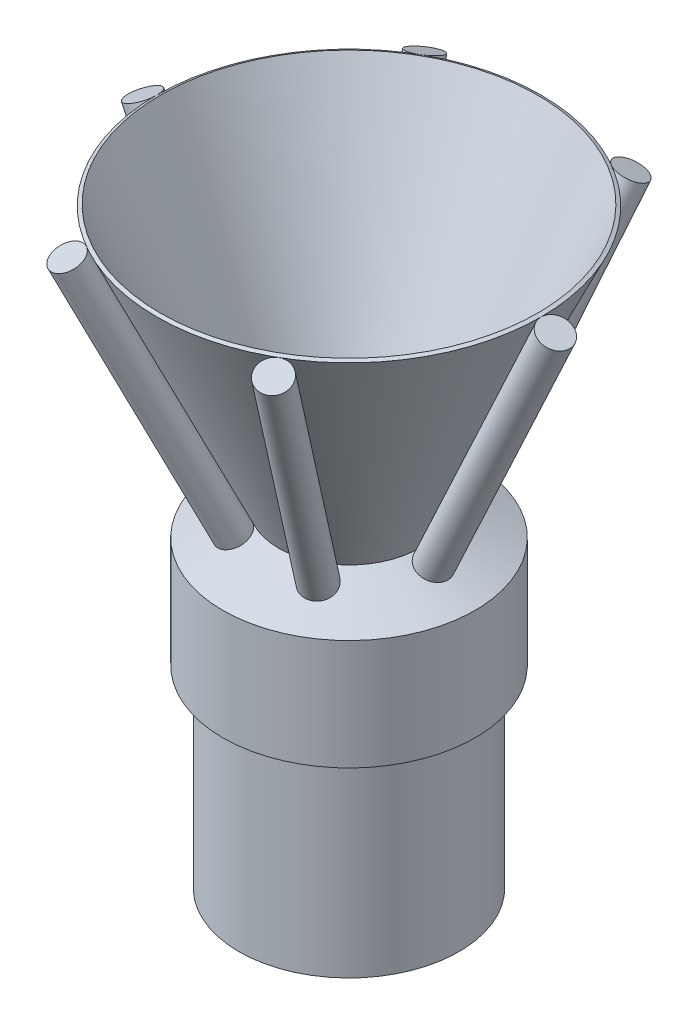
from build123d import *

# Parameters (mm, degrees)
SKETCH1_R           = 175
SKETCH1_R_2         = 75
BOSS_EXTRUDE1_DEPTH = 457
SKETCH3_R           = 25
CUT_EXTRUDE1_DEPTH  = 50
CIRPATTERN1_COUNT   = 6
SKETCH4_R           = 25
BOSS_EXTRUDE2_DEPTH = 508
CIRPATTERN2_COUNT   = 6


with BuildPart() as part:
    # Sketch1 → Boss-Extrude1 (new body)
    with BuildSketch(Plane(origin=(0, 0, 0), x_dir=(1, 0, 0), z_dir=(0, 1, 0))):
        Circle(SKETCH1_R)
        Circle(SKETCH1_R_2, mode=Mode.SUBTRACT)
    extrude(amount=BOSS_EXTRUDE1_DEPTH)

    # Sketch2 → Revolve1 (revolve)
    with BuildSketch(Plane.XY):
        Polygon((-175, 307), (-200.4, 307), (-200.4, 482.4), (-107.12583228, 525.894458716), (-75, 457), (-175, 457), align=None)
    revolve(axis=Axis((0, 0, 0), (0, 1, 0)))

    # Sketch3 → Cut-Extrude1 (cut)
    with BuildSketch(Plane(origin=(220.56260119, 472.998024657, 0), x_dir=(0.906307787, -0.422618262, 0), z_dir=(0.422618262, 0.906307787, 0))):
        with Locations((-95, 0)):
            Circle(SKETCH3_R)
    cut_extrude1 = extrude(amount=-CUT_EXTRUDE1_DEPTH, mode=Mode.SUBTRACT)

    # CirPattern1: Cut-Extrude1 ×6 about axis
    cirpattern1_axis = Axis((0, 0, 0), (0, 1, 0))
    for i in range(1, CIRPATTERN1_COUNT):
        add(cut_extrude1.rotate(cirpattern1_axis, i * 360 / CIRPATTERN1_COUNT), mode=Mode.SUBTRACT)

    # Sketch4 → Boss-Extrude2 (add)
    with BuildSketch(Plane(origin=(-199.431688103, 427.682635305, 0), x_dir=(0.906307787, 0.422618262, 0), z_dir=(-0.422618262, 0.906307787, 0))):
        with Locations((95, 0)):
            Circle(SKETCH4_R)
    boss_extrude2 = extrude(amount=BOSS_EXTRUDE2_DEPTH)

    # CirPattern2: Boss-Extrude2 ×6 about axis
    cirpattern2_axis = Axis((0, 0, 0), (0, 1, 0))
    for i in range(1, CIRPATTERN2_COUNT):
        add(boss_extrude2.rotate(cirpattern2_axis, i * 360 / CIRPATTERN2_COUNT))


with BuildPart() as body_2:
    # Sketch7 → Revolve2 (revolve)
    with BuildSketch(Plane.XY):
        Polygon((-111.805666745, 523.712216066), (-305.364830623, 938.801182529), (-299.9269839, 941.336892099), (-106.415237078, 526.349611839), align=None)
    revolve(axis=Axis((0, 457, 0), (0, -1, 0)))


solid = Compound([part.part, body_2.part])
